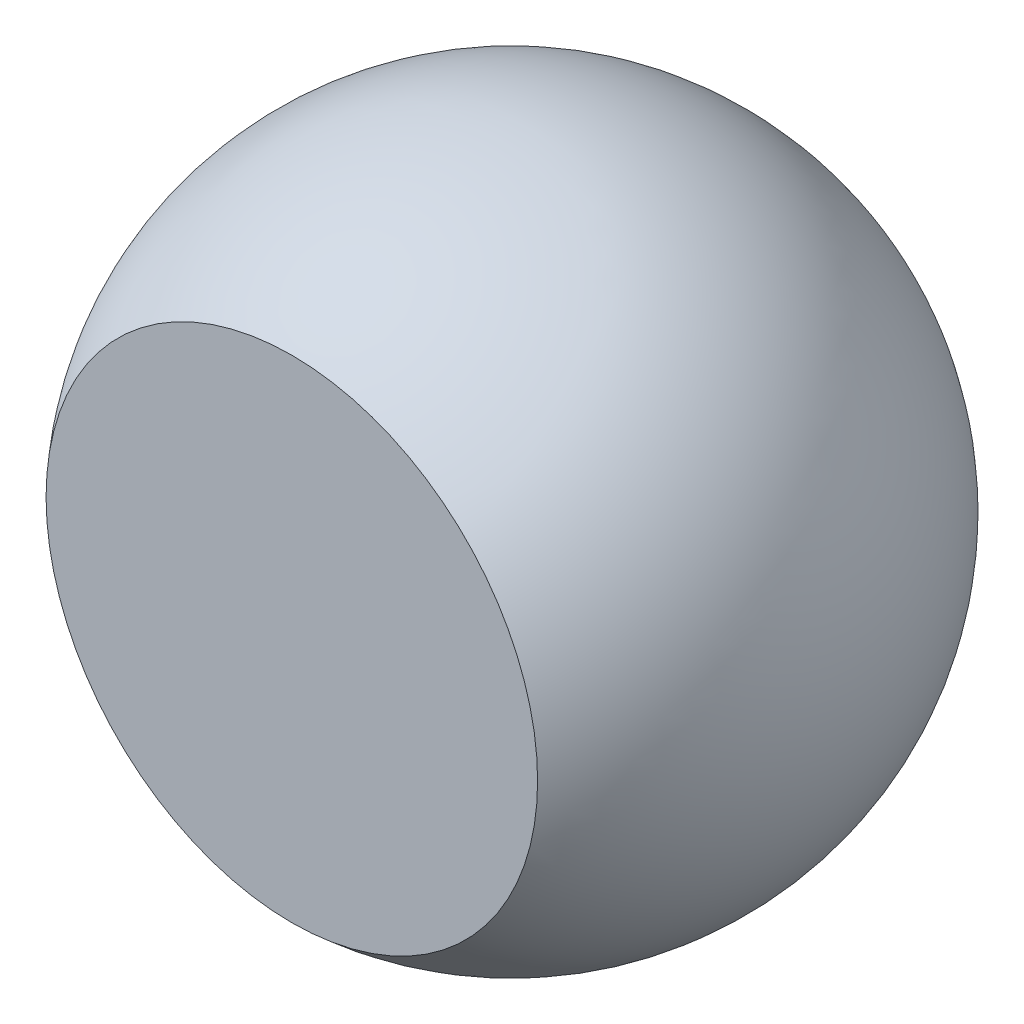
from build123d import *


with BuildPart() as part:
    # Эскиз1 → Повернуть1 (revolve)
    with BuildSketch(Plane(origin=(0, 0, 0), x_dir=(1, 0, 0), z_dir=(0, 1, 0))):
        with BuildLine():
            Line((0, 0.3), (0, -0.2))
            Line((0, -0.2), (0.223606798, -0.2))
            ThreePointArc((0.223606798, -0.2), (0.273861279, 0.122474487), (0, 0.3))
        make_face()
    revolve(axis=Axis((0, 0, -0.377265876), (0, 0, 1)))


solid = part.part
